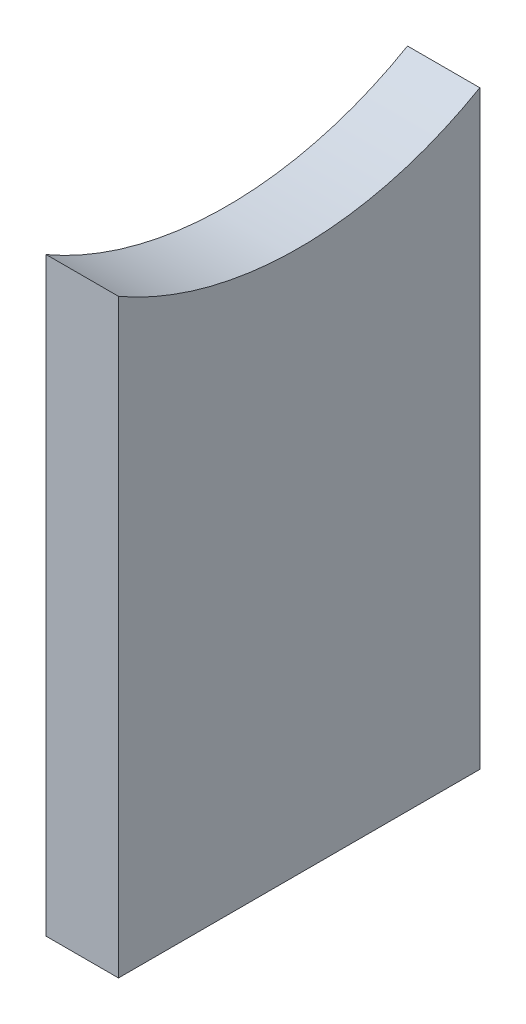
from build123d import *

# Parameters (mm, degrees)
BOSS_EXTRUDE1_DEPTH = 5.08


with BuildPart() as part:
    # Sketch1 → Boss-Extrude1 (new body)
    with BuildSketch(Plane(origin=(0, 0, 0), x_dir=(0, 0, -1), z_dir=(1, 0, 0))):
        with BuildLine():
            Line((0, 0), (25.4, 0))
            Line((25.4, 0), (25.4, 41.502954744))
            ThreePointArc((25.4, 41.502954744), (12.7, 38.1), (0, 41.502954744))
            Line((0, 41.502954744), (0, 0))
        make_face()
    extrude(amount=BOSS_EXTRUDE1_DEPTH)


solid = part.part
